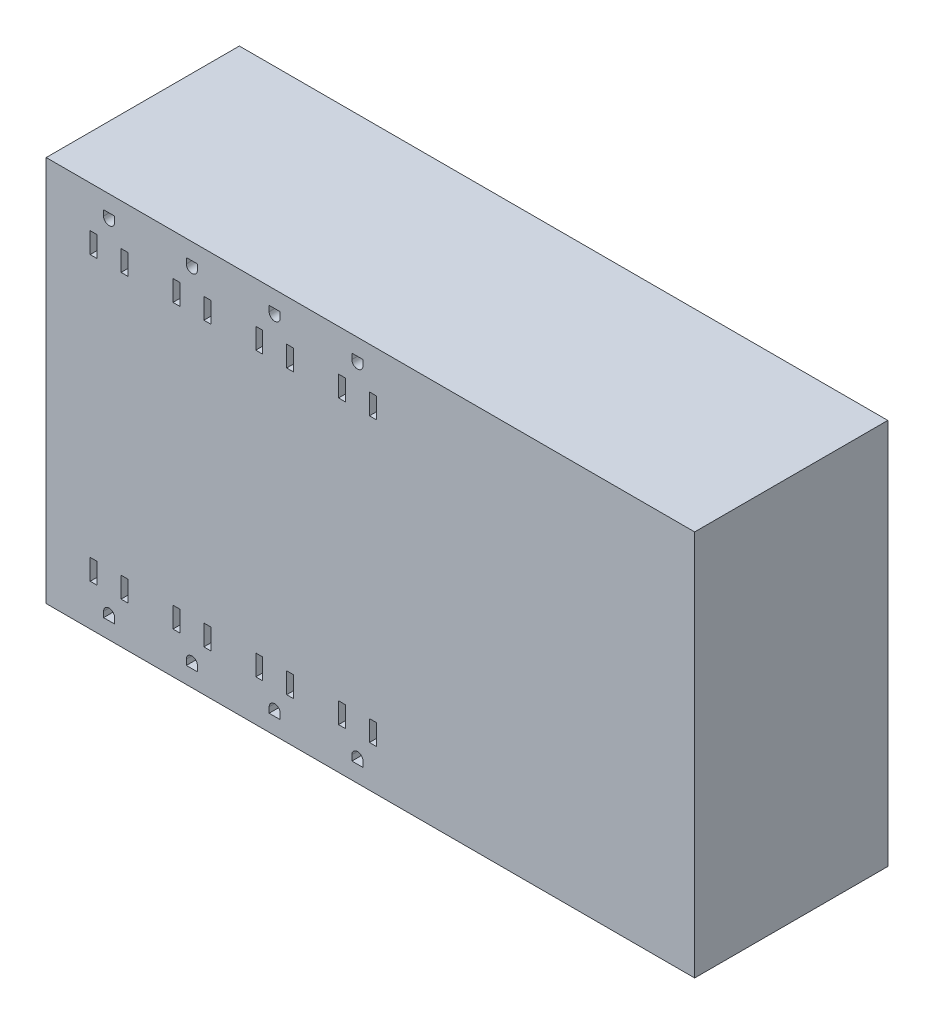
from build123d import *

# Parameters (mm, degrees)
SKETCH1_W           = 298.45
SKETCH1_H           = 177.8
BOSS_EXTRUDE1_DEPTH = 88.9
SKETCH2_W           = 3.175
SKETCH2_H           = 9.525
CUT_EXTRUDE1_DEPTH  = 12.7


with BuildPart() as part:
    # Sketch1 → Boss-Extrude1 (new body)
    with BuildSketch(Plane.XY):
        Rectangle(SKETCH1_W, SKETCH1_H)
    extrude(amount=BOSS_EXTRUDE1_DEPTH)

    # Sketch2 → Cut-Extrude1 (cut)
    with BuildSketch(Plane.XY.offset(88.9)):
        with Locations((-113.159227622, 65.102829303)):
            Rectangle(SKETCH2_W, SKETCH2_H)
        with Locations((-127.383227622, 65.102829303)):
            Rectangle(SKETCH2_W, SKETCH2_H)
        with Locations((-75.059227622, 65.102829303)):
            Rectangle(SKETCH2_W, SKETCH2_H)
        with Locations((-89.283227622, 65.102829303)):
            Rectangle(SKETCH2_W, SKETCH2_H)
        with BuildLine():
            Line((-122.811227622, 81.295329303), (-117.731227622, 81.295329303))
            Line((-117.731227622, 81.295329303), (-117.731227622, 78.755329303))
            ThreePointArc((-117.731227622, 78.755329303), (-120.271227622, 76.215329303), (-122.811227622, 78.755329303))
            Line((-122.811227622, 78.755329303), (-122.811227622, 81.295329303))
        make_face()
        with BuildLine():
            Line((-84.711227622, 81.295329303), (-79.631227622, 81.295329303))
            Line((-79.631227622, 81.295329303), (-79.631227622, 78.755329303))
            ThreePointArc((-79.631227622, 78.755329303), (-82.171227622, 76.215329303), (-84.711227622, 78.755329303))
            Line((-84.711227622, 78.755329303), (-84.711227622, 81.295329303))
        make_face()
        with Locations((-36.959227622, 65.102829303)):
            Rectangle(SKETCH2_W, SKETCH2_H)
        with Locations((-51.183227622, 65.102829303)):
            Rectangle(SKETCH2_W, SKETCH2_H)
        with BuildLine():
            Line((-46.611227622, 81.295329303), (-41.531227622, 81.295329303))
            Line((-41.531227622, 81.295329303), (-41.531227622, 78.755329303))
            ThreePointArc((-41.531227622, 78.755329303), (-44.071227622, 76.215329303), (-46.611227622, 78.755329303))
            Line((-46.611227622, 78.755329303), (-46.611227622, 81.295329303))
        make_face()
        with Locations((1.140772378, 65.102829303)):
            Rectangle(SKETCH2_W, SKETCH2_H)
        with Locations((-13.083227622, 65.102829303)):
            Rectangle(SKETCH2_W, SKETCH2_H)
        with BuildLine():
            Line((-8.511227622, 81.295329303), (-3.431227622, 81.295329303))
            Line((-3.431227622, 81.295329303), (-3.431227622, 78.755329303))
            ThreePointArc((-3.431227622, 78.755329303), (-5.971227622, 76.215329303), (-8.511227622, 78.755329303))
            Line((-8.511227622, 78.755329303), (-8.511227622, 81.295329303))
        make_face()
        with BuildLine():
            Line((-3.431227622, -81.295329303), (-3.431227622, -78.755329303))
            ThreePointArc((-3.431227622, -78.755329303), (-5.971227622, -76.215329303), (-8.511227622, -78.755329303))
            Line((-8.511227622, -78.755329303), (-8.511227622, -81.295329303))
            Line((-8.511227622, -81.295329303), (-3.431227622, -81.295329303))
        make_face()
        with Locations((1.140772378, -65.102829303)):
            Rectangle(SKETCH2_W, SKETCH2_H)
        with Locations((-13.083227622, -65.102829303)):
            Rectangle(SKETCH2_W, SKETCH2_H)
        with BuildLine():
            Line((-41.531227622, -81.295329303), (-41.531227622, -78.755329303))
            ThreePointArc((-41.531227622, -78.755329303), (-44.071227622, -76.215329303), (-46.611227622, -78.755329303))
            Line((-46.611227622, -78.755329303), (-46.611227622, -81.295329303))
            Line((-46.611227622, -81.295329303), (-41.531227622, -81.295329303))
        make_face()
        with Locations((-36.959227622, -65.102829303)):
            Rectangle(SKETCH2_W, SKETCH2_H)
        with Locations((-51.183227622, -65.102829303)):
            Rectangle(SKETCH2_W, SKETCH2_H)
        with BuildLine():
            Line((-79.631227622, -81.295329303), (-79.631227622, -78.755329303))
            ThreePointArc((-79.631227622, -78.755329303), (-82.171227622, -76.215329303), (-84.711227622, -78.755329303))
            Line((-84.711227622, -78.755329303), (-84.711227622, -81.295329303))
            Line((-84.711227622, -81.295329303), (-79.631227622, -81.295329303))
        make_face()
        with Locations((-75.059227622, -65.102829303)):
            Rectangle(SKETCH2_W, SKETCH2_H)
        with Locations((-89.283227622, -65.102829303)):
            Rectangle(SKETCH2_W, SKETCH2_H)
        with BuildLine():
            Line((-117.731227622, -81.295329303), (-117.731227622, -78.755329303))
            ThreePointArc((-117.731227622, -78.755329303), (-120.271227622, -76.215329303), (-122.811227622, -78.755329303))
            Line((-122.811227622, -78.755329303), (-122.811227622, -81.295329303))
            Line((-122.811227622, -81.295329303), (-117.731227622, -81.295329303))
        make_face()
        with Locations((-113.159227622, -65.102829303)):
            Rectangle(SKETCH2_W, SKETCH2_H)
        with Locations((-127.383227622, -65.102829303)):
            Rectangle(SKETCH2_W, SKETCH2_H)
    extrude(amount=-CUT_EXTRUDE1_DEPTH, mode=Mode.SUBTRACT)


solid = part.part
